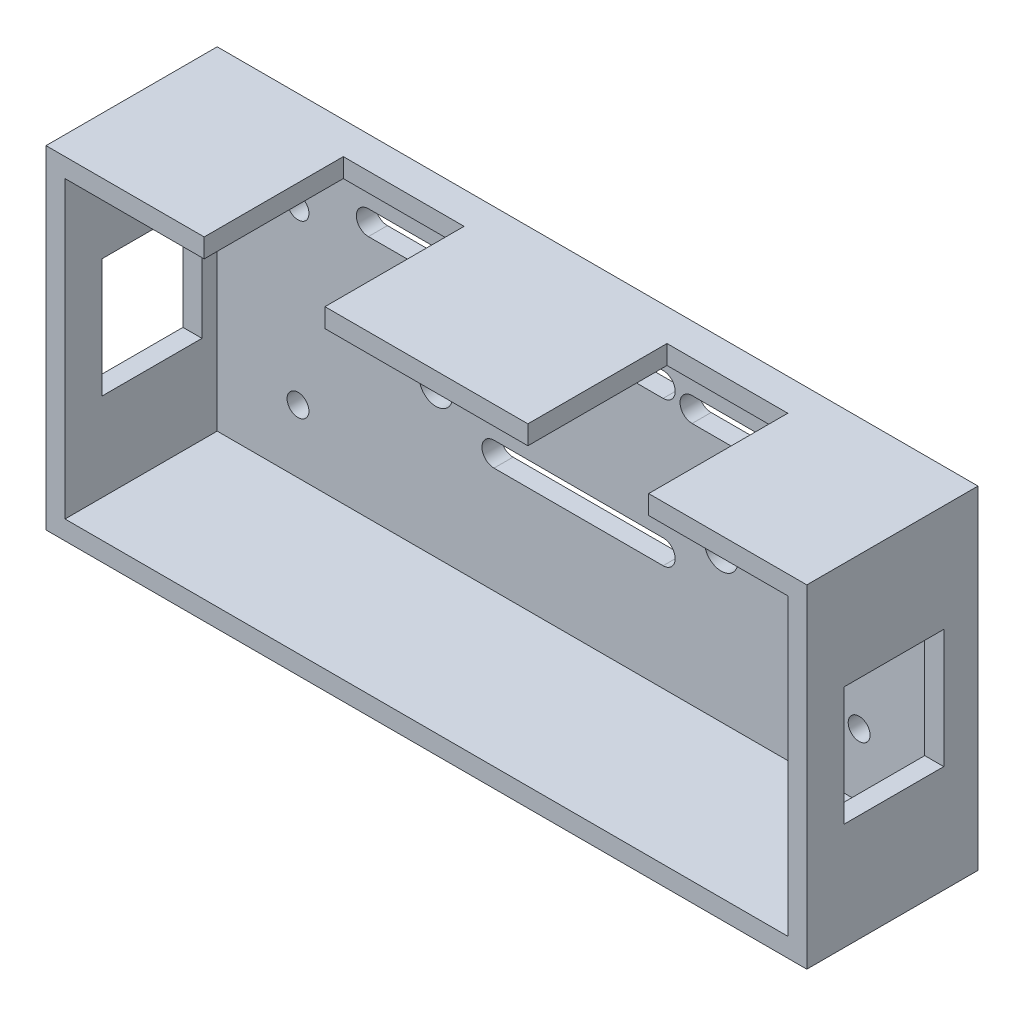
from build123d import *

# Parameters (mm, degrees)
SKETCH_1_W          = 80
SKETCH_1_H          = 35
EXTRUDE_1_DEPTH     = 2
SKETCH_2_W          = 80
SKETCH_2_H          = 35
SKETCH_2_W_2        = 76
SKETCH_2_H_2        = 31
EXTRUDE_2_DEPTH     = 16
SKETCH_3_W          = 10.5
SKETCH_3_H          = 12.5
CUT_EXTRUDE_1_DEPTH = 81
SKETCH_4_R          = 1.15
SKETCH_4_R_2        = 1.75
CUT_EXTRUDE_2_DEPTH = 3
CUT_EXTRUDE_3_DEPTH = 19
CUT_EXTRUDE_4_REACH = 37
SKETCH_6_W          = 12.7
SKETCH_6_H          = 3
CUT_EXTRUDE_5_REACH = 37
SKETCH_7_W          = 12.7
SKETCH_7_H          = 11.63


with BuildPart() as part:
    # 草图1 → 凸台-拉伸1 (new body)
    with BuildSketch(Plane.XY):
        Rectangle(SKETCH_1_W, SKETCH_1_H)
    extrude(amount=EXTRUDE_1_DEPTH)

    # 草图2 → 凸台-拉伸2 (add)
    with BuildSketch(Plane.XY.offset(2)):
        Rectangle(SKETCH_2_W, SKETCH_2_H)
        Rectangle(SKETCH_2_W_2, SKETCH_2_H_2, mode=Mode.SUBTRACT)
    extrude(amount=EXTRUDE_2_DEPTH)

    # 草图3 → 切除-拉伸1 (cut, through all)
    with BuildSketch(Plane.ZY.offset(40)):
        with Locations((8.85, 0)):
            Rectangle(SKETCH_3_W, SKETCH_3_H)
    extrude(amount=-CUT_EXTRUDE_1_DEPTH, mode=Mode.SUBTRACT)

    # 草图4 → 切除-拉伸2 (cut, through all)
    with BuildSketch(Plane.XY.offset(2)):
        with Locations((-29.5, 9.140333749)):
            Circle(SKETCH_4_R)
        with Locations((-29.5, -8.859666251)):
            Circle(SKETCH_4_R)
        with Locations((29.5, 9.140333749)):
            Circle(SKETCH_4_R)
        with Locations((29.5, -8.859666251)):
            Circle(SKETCH_4_R)
        with Locations((-15, 0)):
            Circle(SKETCH_4_R_2)
        with Locations((15, 0)):
            Circle(SKETCH_4_R_2)
    extrude(amount=-CUT_EXTRUDE_2_DEPTH, mode=Mode.SUBTRACT)

    # 草图5 → 切除-拉伸3 (cut, through all)
    with BuildSketch(Plane(origin=(0, 0, 0), x_dir=(-1, 0, 0), z_dir=(0, 0, -1))):
        with BuildLine():
            Line((-8.89, 13.468), (8.89, 13.468))
            ThreePointArc((8.89, 13.468), (10.16, 12.198), (8.89, 10.928))
            Line((8.89, 10.928), (-8.89, 10.928))
            ThreePointArc((-8.89, 10.928), (-10.16, 12.198), (-8.89, 13.468))
        make_face()
        with BuildLine():
            Line((-8.89, -1.772), (8.89, -1.772))
            ThreePointArc((8.89, -1.772), (10.16, -3.042), (8.89, -4.312))
            Line((8.89, -4.312), (-8.89, -4.312))
            ThreePointArc((-8.89, -4.312), (-10.16, -3.042), (-8.89, -1.772))
        make_face()
        with BuildLine():
            Line((-22.098, 12.706), (-11.938, 12.706))
            ThreePointArc((-11.938, 12.706), (-10.668, 11.436), (-11.938, 10.166))
            Line((-11.938, 10.166), (-22.098, 10.166))
            ThreePointArc((-22.098, 10.166), (-23.368, 11.436), (-22.098, 12.706))
        make_face()
        with BuildLine():
            Line((11.94, 12.706), (22.1, 12.706))
            ThreePointArc((22.1, 12.706), (23.37, 11.436), (22.1, 10.166))
            Line((22.1, 10.166), (11.94, 10.166))
            ThreePointArc((11.94, 10.166), (10.67, 11.436), (11.94, 12.706))
        make_face()
    extrude(amount=-CUT_EXTRUDE_3_DEPTH, mode=Mode.SUBTRACT)

    # 草图6 → 切除-拉伸4 (cut, up to next)
    with BuildSketch(Plane(origin=(0, 17.5, 0), x_dir=(1, 0, 0), z_dir=(0, 1, 0)), mode=Mode.PRIVATE) as cut_extrude_4_sk1:
        with Locations((-17.018, -4.87)):
            Rectangle(SKETCH_6_W, SKETCH_6_H)
    cut_extrude_4_tool1 = extrude(cut_extrude_4_sk1.sketch, amount=-CUT_EXTRUDE_4_REACH, mode=Mode.PRIVATE) & part.part
    add(cut_extrude_4_tool1.solids().sort_by_distance((-17.018, 17.5, 4.87))[0], mode=Mode.SUBTRACT)
    # 草图6 → 切除-拉伸4 (cut, up to next)
    with BuildSketch(Plane(origin=(0, 17.5, 0), x_dir=(1, 0, 0), z_dir=(0, 1, 0)), mode=Mode.PRIVATE) as cut_extrude_4_sk2:
        with Locations((17.02, -4.87)):
            Rectangle(SKETCH_6_W, SKETCH_6_H)
    cut_extrude_4_tool2 = extrude(cut_extrude_4_sk2.sketch, amount=-CUT_EXTRUDE_4_REACH, mode=Mode.PRIVATE) & part.part
    add(cut_extrude_4_tool2.solids().sort_by_distance((17.02, 17.5, 4.87))[0], mode=Mode.SUBTRACT)

    # 草图7 → 切除-拉伸5 (cut, up to next)
    with BuildSketch(Plane(origin=(0, 17.5, 0), x_dir=(1, 0, 0), z_dir=(0, 1, 0)), mode=Mode.PRIVATE) as cut_extrude_5_sk1:
        with Locations((-17.018, -12.185)):
            Rectangle(SKETCH_7_W, SKETCH_7_H)
    cut_extrude_5_tool1 = extrude(cut_extrude_5_sk1.sketch, amount=-CUT_EXTRUDE_5_REACH, mode=Mode.PRIVATE) & part.part
    add(cut_extrude_5_tool1.solids().sort_by_distance((-17.018, 17.5, 12.185))[0], mode=Mode.SUBTRACT)
    # 草图7 → 切除-拉伸5 (cut, up to next)
    with BuildSketch(Plane(origin=(0, 17.5, 0), x_dir=(1, 0, 0), z_dir=(0, 1, 0)), mode=Mode.PRIVATE) as cut_extrude_5_sk2:
        with Locations((17.02, -12.185)):
            Rectangle(SKETCH_7_W, SKETCH_7_H)
    cut_extrude_5_tool2 = extrude(cut_extrude_5_sk2.sketch, amount=-CUT_EXTRUDE_5_REACH, mode=Mode.PRIVATE) & part.part
    add(cut_extrude_5_tool2.solids().sort_by_distance((17.02, 17.5, 12.185))[0], mode=Mode.SUBTRACT)


solid = part.part
